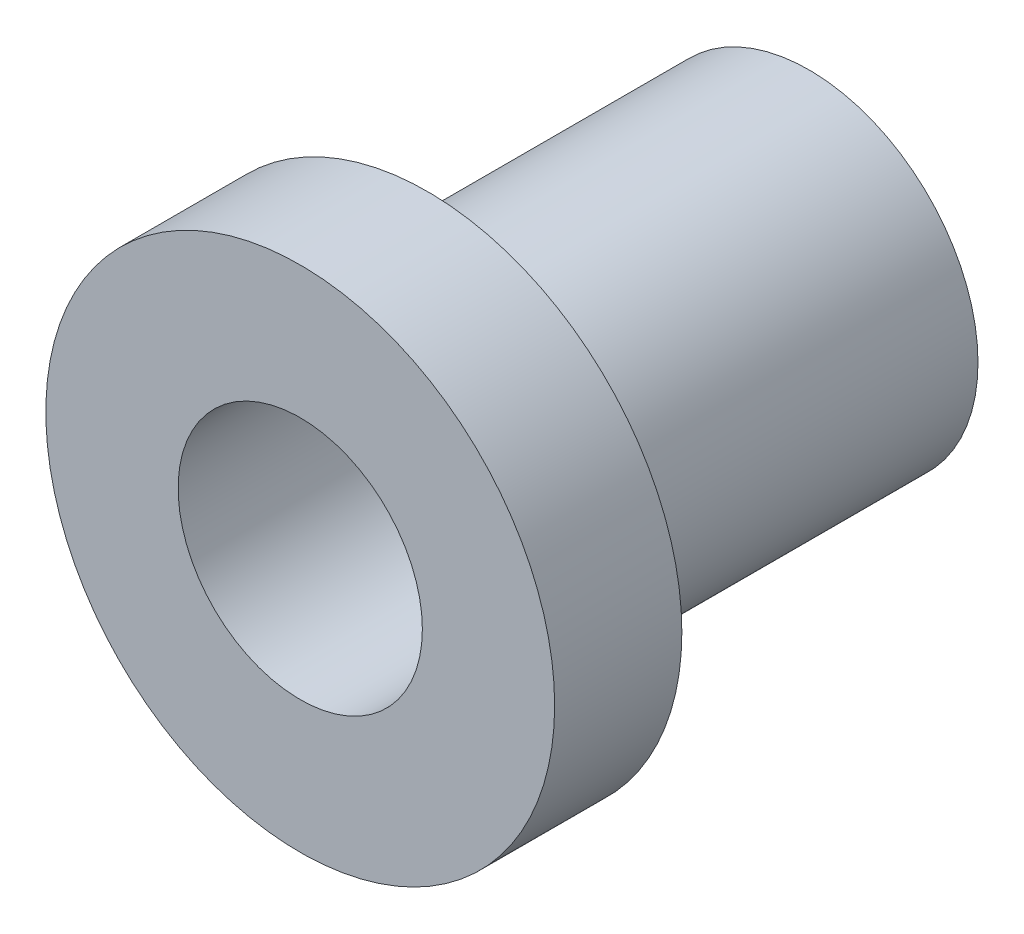
from build123d import *

# Parameters (mm, degrees)
SKETCH1_R           = 4.2164
BOSS_EXTRUDE1_DEPTH = 9.525
SKETCH2_R           = 6.35
BOSS_EXTRUDE2_DEPTH = 3.175
SKETCH3_R           = 3.048
CUT_EXTRUDE1_DEPTH  = 13.7


with BuildPart() as part:
    # Sketch1 → Boss-Extrude1 (new body)
    with BuildSketch(Plane.XY):
        Circle(SKETCH1_R)
    extrude(amount=BOSS_EXTRUDE1_DEPTH)

    # Sketch2 → Boss-Extrude2 (add)
    with BuildSketch(Plane.XY.offset(9.525)):
        Circle(SKETCH2_R)
    extrude(amount=BOSS_EXTRUDE2_DEPTH)

    # Sketch3 → Cut-Extrude1 (cut, through all)
    with BuildSketch(Plane.XY.offset(12.7)):
        Circle(SKETCH3_R)
    extrude(amount=-CUT_EXTRUDE1_DEPTH, mode=Mode.SUBTRACT)


solid = part.part
